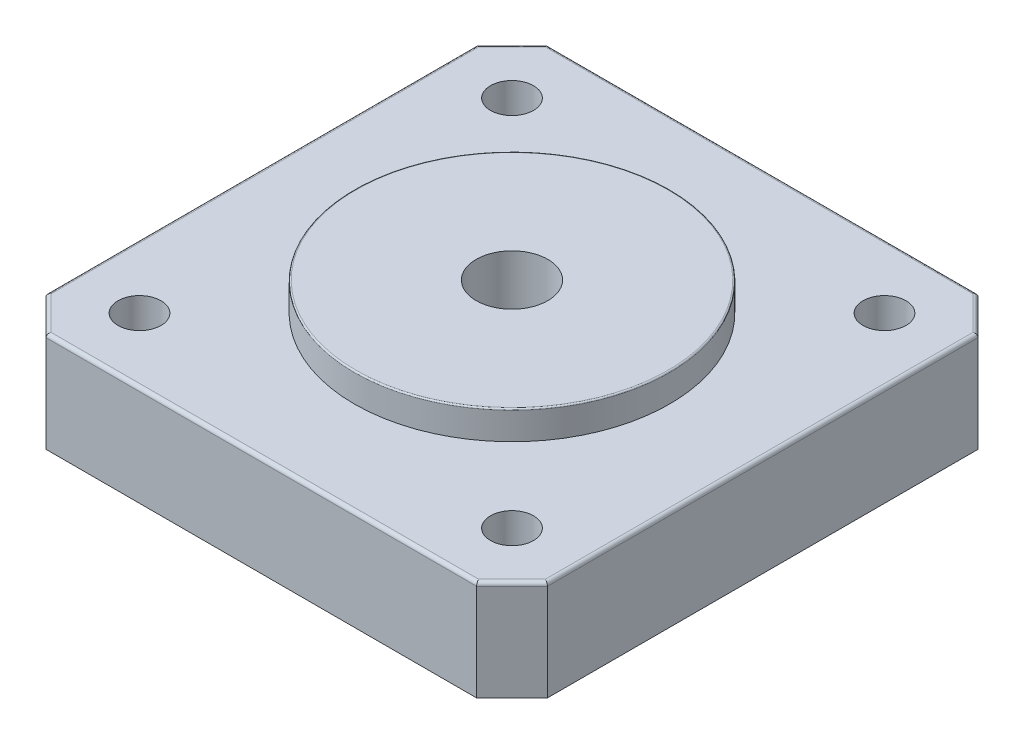
from build123d import *

# Parameters (mm, degrees)
SALIENTE_EXTRUIR1_DEPTH = 7
CROQUIS2_R              = 2.5
CORTAR_EXTRUIR1_DEPTH   = 8
CROQUIS3_R              = 1.5
CORTAR_EXTRUIR2_DEPTH   = 8
CROQUIS4_R              = 11
CROQUIS4_R_2            = 2.5
SALIENTE_EXTRUIR2_DEPTH = 2
REDONDEO1_R             = 0.1
REDONDEO3_R             = 0.25


with BuildPart() as part:
    # Croquis1 → Saliente-Extruir1 (new body)
    with BuildSketch(Plane(origin=(0, 0, 0), x_dir=(1, 0, 0), z_dir=(0, 1, 0))):
        Polygon((0, 32.526911935), (2.473088065, 35), (32.526911935, 35), (35, 32.526911935), (35, 2.473088065), (32.526911935, 0), (2.473088065, 0), (0, 2.473088065), align=None)
    extrude(amount=SALIENTE_EXTRUIR1_DEPTH)

    # Croquis2 → Cortar-Extruir1 (cut, through all)
    with BuildSketch(Plane(origin=(0, 7, 0), x_dir=(1, 0, 0), z_dir=(0, 1, 0))):
        with Locations((17.5, 17.5)):
            Circle(CROQUIS2_R)
    extrude(amount=-CORTAR_EXTRUIR1_DEPTH, mode=Mode.SUBTRACT)

    # Croquis3 → Cortar-Extruir2 (cut, through all)
    with BuildSketch(Plane(origin=(0, 7, 0), x_dir=(1, 0, 0), z_dir=(0, 1, 0))):
        with Locations((4.5, 30.5)):
            Circle(CROQUIS3_R)
        with Locations((30.5, 30.5)):
            Circle(CROQUIS3_R)
        with Locations((30.5, 4.5)):
            Circle(CROQUIS3_R)
        with Locations((4.5, 4.5)):
            Circle(CROQUIS3_R)
    extrude(amount=-CORTAR_EXTRUIR2_DEPTH, mode=Mode.SUBTRACT)

    # Croquis4 → Saliente-Extruir2 (add)
    with BuildSketch(Plane(origin=(0, 7, 0), x_dir=(1, 0, 0), z_dir=(0, 1, 0))):
        with Locations((17.5, 17.5)):
            Circle(CROQUIS4_R)
        with Locations((17.5, 17.5)):
            Circle(CROQUIS4_R_2, mode=Mode.SUBTRACT)
    extrude(amount=SALIENTE_EXTRUIR2_DEPTH)

    # Redondeo1
    redondeo1_edges = [part.edges().sort_by_distance(p)[0] for p in [
        (6.5, 9, -17.5),
    ]]
    fillet(redondeo1_edges, radius=REDONDEO1_R)

    # Redondeo3
    redondeo3_edges = [part.edges().sort_by_distance(p)[0] for p in [
        (17.5, 7, 0),
        (33.763455967, 7, -1.236544033),
        (35, 7, -17.5),
        (33.763455967, 7, -33.763455967),
        (17.5, 7, -35),
        (1.236544033, 7, -33.763455967),
        (0, 7, -17.5),
        (1.236544033, 7, -1.236544033),
    ]]
    fillet(redondeo3_edges, radius=REDONDEO3_R)


solid = part.part
